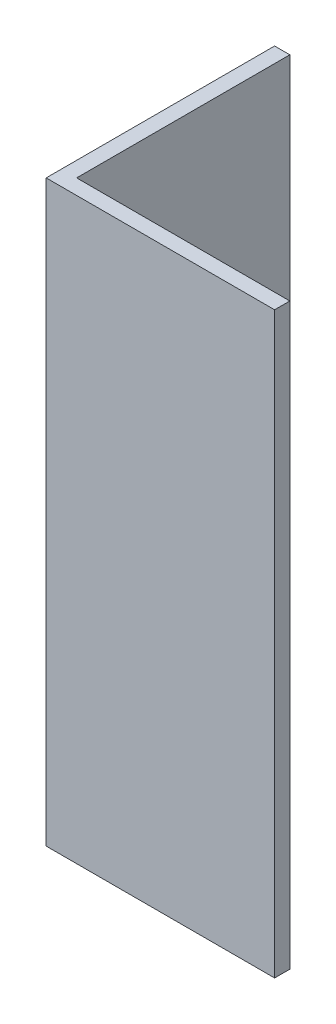
from build123d import *

# Parameters (mm, degrees)
EXTRUDE_1_DEPTH = 38


with BuildPart() as part:
    # Эскиз1 → Бобышка-Вытянуть1 (new body)
    with BuildSketch(Plane(origin=(0, 0, 0), x_dir=(1, 0, 0), z_dir=(0, 1, 0))):
        Polygon((0, 0), (0, 15), (1, 15), (1, 1), (15, 1), (15, 0), align=None)
    extrude(amount=EXTRUDE_1_DEPTH)


solid = part.part
